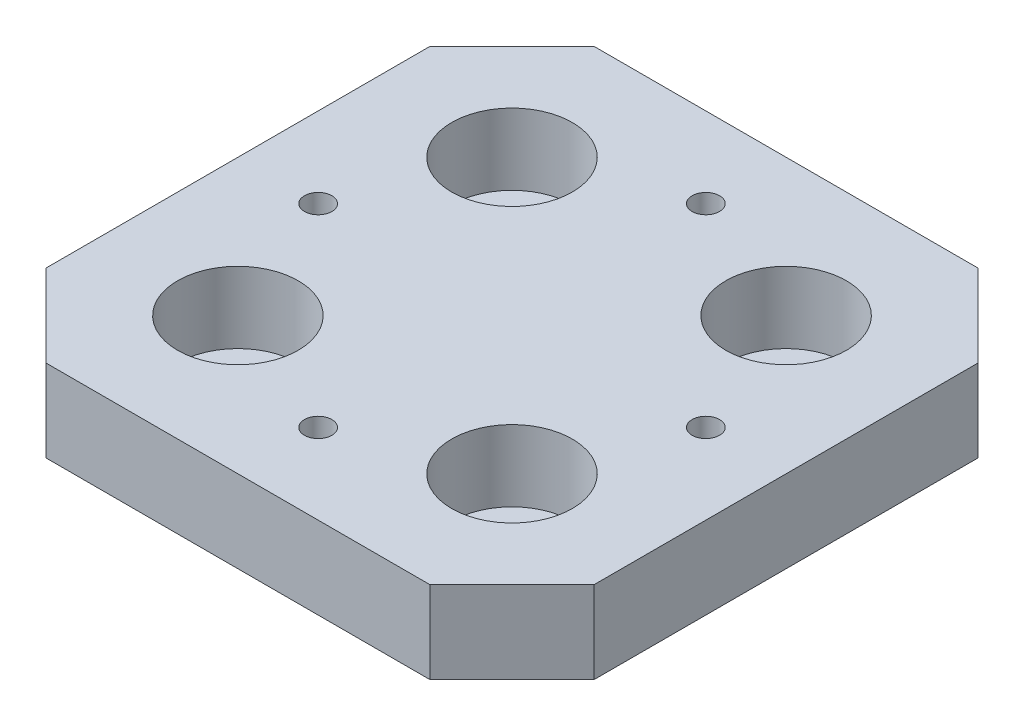
from build123d import *

# Parameters (mm, degrees)
SKETCH1_W                                           = 50
SKETCH1_H                                           = 50
BOSS_EXTRUDE1_DEPTH                                 = 7.5
CBORE_FOR_M6_HEX_SOCKET_HEAD_CAP_SCREW1_D           = 6.6
CBORE_FOR_M6_HEX_SOCKET_HEAD_CAP_SCREW1_DEPTH       = 7.5
CBORE_FOR_M6_HEX_SOCKET_HEAD_CAP_SCREW1_CBORE_D     = 11
CBORE_FOR_M6_HEX_SOCKET_HEAD_CAP_SCREW1_CBORE_DEPTH = 6.5
M3_TAPPED_HOLE1_D                                   = 2.5
M3_TAPPED_HOLE1_DEPTH                               = 7.5
CHAMFER1_SIZE                                       = 7.5


with BuildPart() as part:
    # Sketch1 → Boss-Extrude1 (new body)
    with BuildSketch(Plane(origin=(0, 0, 0), x_dir=(1, 0, 0), z_dir=(0, 1, 0))):
        Rectangle(SKETCH1_W, SKETCH1_H)
    extrude(amount=BOSS_EXTRUDE1_DEPTH)

    # CBORE for M6 Hex Socket Head Cap Screw1
    with Locations(Plane(origin=(0, 7.5, 0), x_dir=(1, 0, 0), z_dir=(0, 1, 0))):
        with Locations((-12.5, -12.5), (-12.5, 12.5), (12.5, 12.5), (12.5, -12.5)):
            CounterBoreHole(CBORE_FOR_M6_HEX_SOCKET_HEAD_CAP_SCREW1_D / 2, CBORE_FOR_M6_HEX_SOCKET_HEAD_CAP_SCREW1_CBORE_D / 2, CBORE_FOR_M6_HEX_SOCKET_HEAD_CAP_SCREW1_CBORE_DEPTH, depth=CBORE_FOR_M6_HEX_SOCKET_HEAD_CAP_SCREW1_DEPTH)

    # M3 Tapped Hole1
    with Locations(Plane(origin=(0, 7.5, 0), x_dir=(1, 0, 0), z_dir=(0, 1, 0))):
        with Locations((0, 17.67766953), (-17.67766953, 0), (0, -17.67766953), (17.67766953, 0)):
            Hole(M3_TAPPED_HOLE1_D / 2, depth=M3_TAPPED_HOLE1_DEPTH)

    # Chamfer1
    chamfer1_edges = [part.edges().sort_by_distance(p)[0] for p in [
        (25, 3.75, 25),
        (-25, 3.75, 25),
        (-25, 3.75, -25),
        (25, 3.75, -25),
    ]]
    chamfer(chamfer1_edges, length=CHAMFER1_SIZE)


solid = part.part
